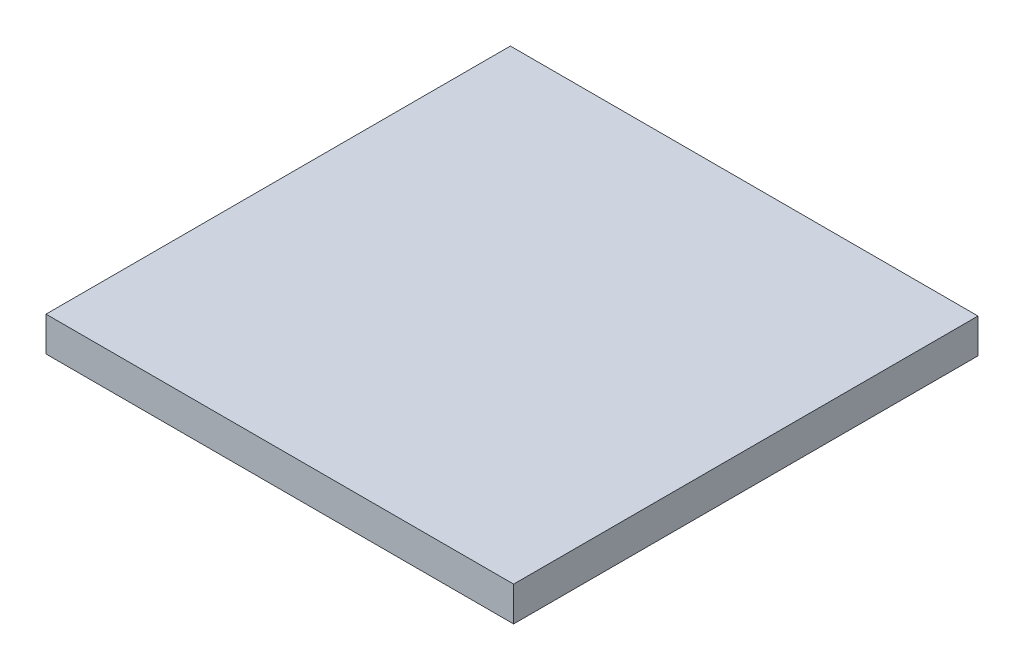
from build123d import *

# Parameters (mm, degrees)
SKETCH1_W           = 34.4068003
SKETCH1_H           = 34.167864186
BOSS_EXTRUDE1_DEPTH = 2.54


with BuildPart() as part:
    # Sketch1 → Boss-Extrude1 (new body)
    with BuildSketch(Plane(origin=(0, 0, 0), x_dir=(1, 0, 0), z_dir=(0, 1, 0))):
        with Locations((-39.066054507, 14.216698735)):
            Rectangle(SKETCH1_W, SKETCH1_H)
    extrude(amount=BOSS_EXTRUDE1_DEPTH)


solid = part.part
